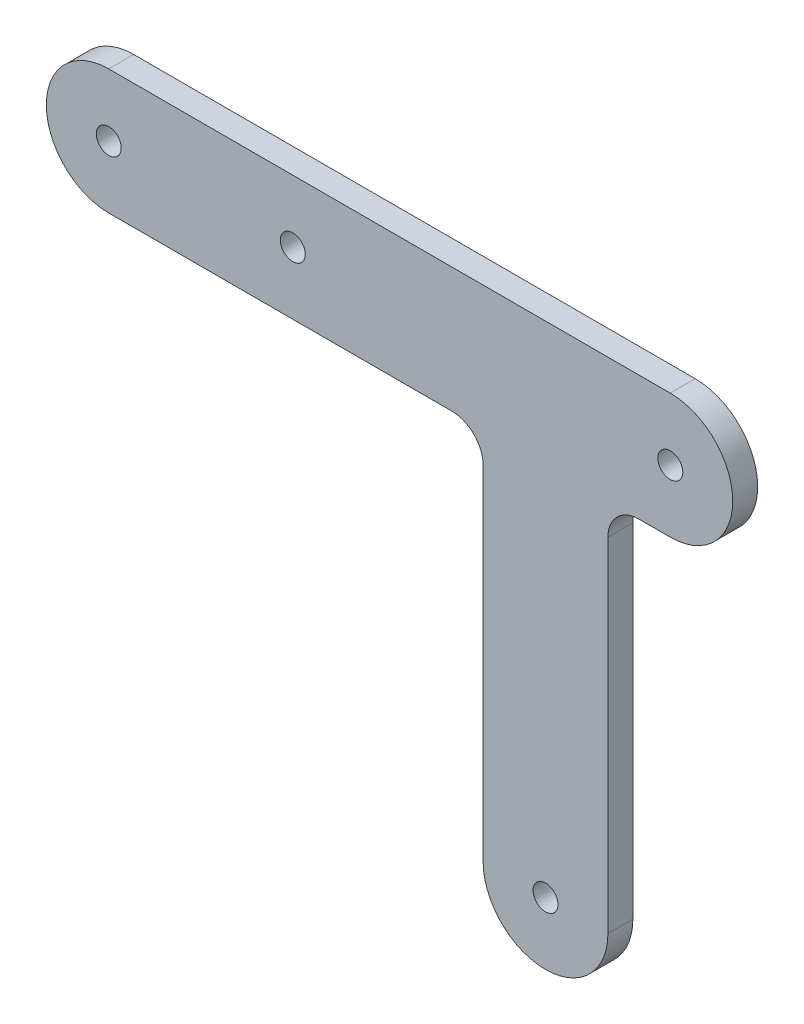
from build123d import *

# Parameters (mm, degrees)
SKETCH_1_R      = 2
EXTRUDE_1_DEPTH = 4


with BuildPart() as part:
    # 草图1 → 凸台-拉伸1 (new body)
    with BuildSketch(Plane.XY):
        with BuildLine():
            Line((-98.108217502, -15.678085124), (-43.108217502, -15.678085124))
            ThreePointArc((-43.108217502, -15.678085124), (-39.572683597, -17.142551218), (-38.108217502, -20.678085124))
            Line((-38.108217502, -20.678085124), (-38.108217502, -75.678085124))
            ThreePointArc((-38.108217502, -75.678085124), (-28.108217502, -85.678085124), (-18.108217502, -75.678085124))
            Line((-18.108217502, -75.678085124), (-18.108217502, -20.678085124))
            ThreePointArc((-18.108217502, -20.678085124), (-16.643751408, -17.142551218), (-13.108217502, -15.678085124))
            Line((-13.108217502, -15.678085124), (-8.108217502, -15.678085124))
            ThreePointArc((-8.108217502, -15.678085124), (1.352773969, -8.916856554), (-1.979819728, 2.223986801))
            ThreePointArc((-1.979819728, 2.223986801), (-4.869446073, 3.782906348), (-8.108217502, 4.321914876))
            Line((-8.108217502, 4.321914876), (-98.108217502, 4.321914876))
            ThreePointArc((-98.108217502, 4.321914876), (-108.108217502, -5.678085124), (-98.108217502, -15.678085124))
        make_face()
        with Locations((-28.108217502, -75.678085124)):
            Circle(SKETCH_1_R, mode=Mode.SUBTRACT)
        with Locations((-98.108217502, -5.678085124)):
            Circle(SKETCH_1_R, mode=Mode.SUBTRACT)
        with Locations((-68.608217502, -5.678085124)):
            Circle(SKETCH_1_R, mode=Mode.SUBTRACT)
        with Locations((-8.108217502, -5.678085124)):
            Circle(SKETCH_1_R, mode=Mode.SUBTRACT)
    extrude(amount=EXTRUDE_1_DEPTH)


solid = part.part
